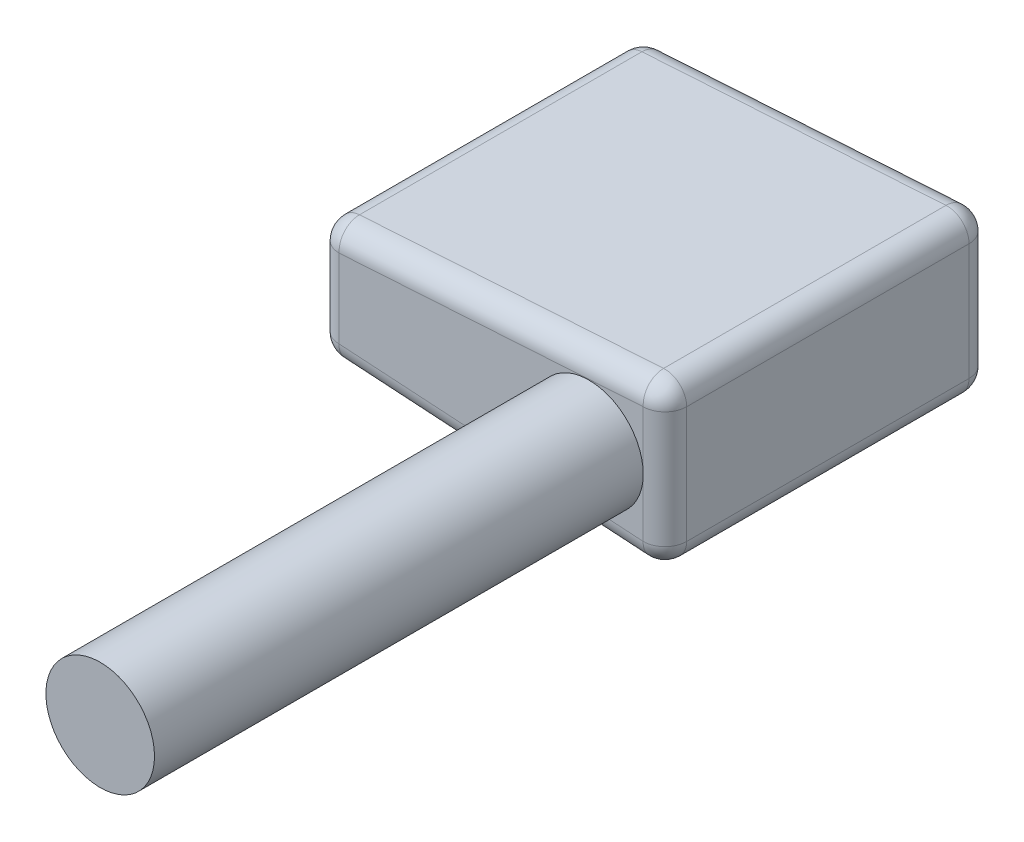
from build123d import *

# Parameters (mm, degrees)
RESSALTO_EXTRUS_O1_DEPTH = 30
FILETE1_R                = 2
ESBO_O4_R                = 5
RESSALTO_EXTRUS_O2_DEPTH = 45


with BuildPart() as part:
    # Esboço2 → Ressalto-extrusão1 (new body)
    with BuildSketch(Plane.XY):
        Polygon((0, 0), (0, 15), (-32, 13), (-32, 2), align=None)
    extrude(amount=RESSALTO_EXTRUS_O1_DEPTH)

    # Filete1
    filete1_edges = [part.edges().sort_by_distance(p)[0] for p in [
        (-16, 14, 30),
        (-32, 7.5, 30),
        (-16, 1, 30),
        (-32, 7.5, 0),
        (-16, 14, 0),
        (0, 7.5, 0),
        (-16, 1, 0),
        (-32, 2, 15),
        (-32, 13, 15),
        (0, 15, 15),
        (0, 0, 15),
        (0, 7.5, 30),
    ]]
    fillet(filete1_edges, radius=FILETE1_R)

    # Esboço4 → Ressalto-extrusão2 (add)
    with BuildSketch(Plane.XY.offset(30)):
        with Locations((-7, 7.5)):
            Circle(ESBO_O4_R)
    extrude(amount=RESSALTO_EXTRUS_O2_DEPTH)


solid = part.part
